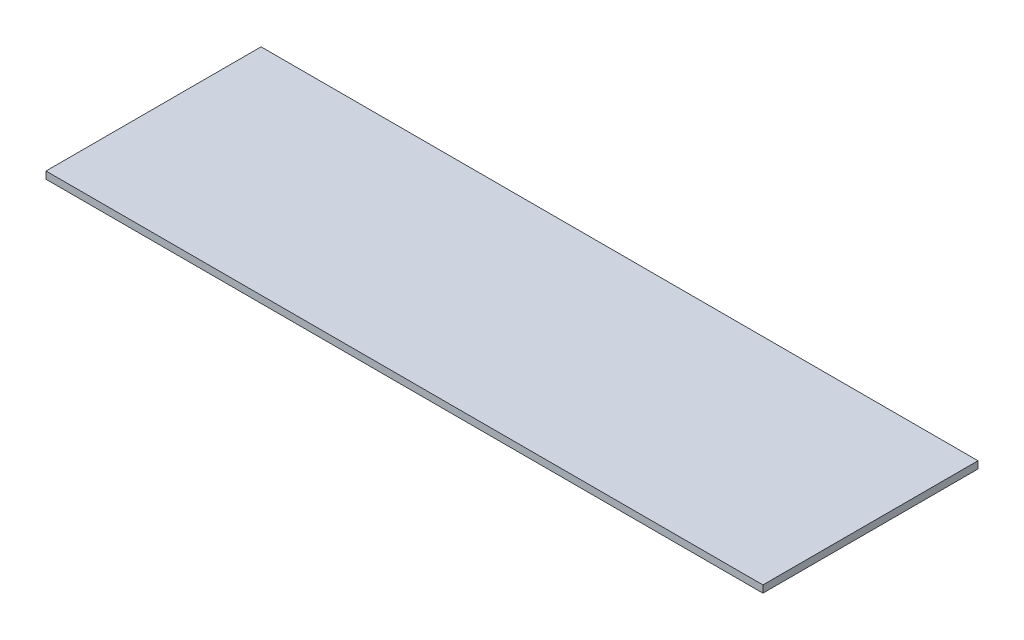
from build123d import *

# Parameters (mm, degrees)
SKETCH1_W      = 1000
SKETCH1_H      = 300
EXTRUDE1_DEPTH = 10


with BuildPart() as part:
    # Sketch1 → Extrude1 (new body)
    with BuildSketch(Plane(origin=(0, 0, 0), x_dir=(1, 0, 0), z_dir=(0, 1, 0))):
        with Locations((-500, 150)):
            Rectangle(SKETCH1_W, SKETCH1_H)
    extrude(amount=EXTRUDE1_DEPTH)


solid = part.part
